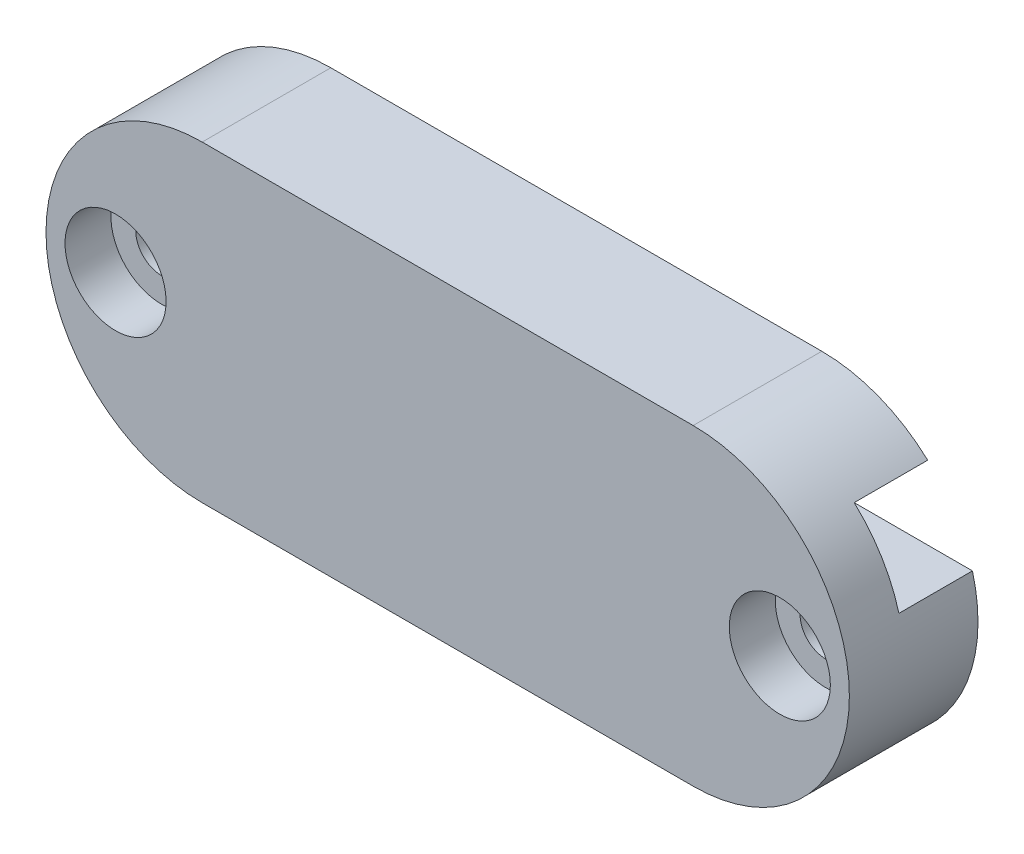
from build123d import *

# Parameters (mm, degrees)
BOSS_EXTRUDE1_DEPTH     = 7
SKETCH3_W               = 8
SKETCH3_H               = 4
CUT_EXTRUDE1_DEPTH      = 6.459407384
CUT_EXTRUDE1_DEPTH_BACK = 39.259407384
SKETCH6_R               = 1.4
CUT_EXTRUDE3_DEPTH      = 1
CUT_EXTRUDE3_DEPTH_BACK = 8
SKETCH8_R               = 2.75
CUT_EXTRUDE4_DEPTH      = 1
CUT_EXTRUDE4_DEPTH_BACK = 2.5


with BuildPart() as part:
    # Sketch1 → Boss-Extrude1 (new body)
    with BuildSketch(Plane.XY):
        with BuildLine():
            Line((-13.359407384, -8.5), (13.359407384, -8.5))
            ThreePointArc((13.359407384, -8.5), (21.859407384, 0), (13.359407384, 8.5))
            Line((13.359407384, 8.5), (-13.359407384, 8.5))
            ThreePointArc((-13.359407384, 8.5), (-21.859407384, 0), (-13.359407384, -8.5))
        make_face()
    extrude(amount=BOSS_EXTRUDE1_DEPTH)

    # Sketch3 → Cut-Extrude1 (cut, two sides)
    with BuildSketch(Plane(origin=(16.4, 0, 0), x_dir=(0, 0, -1), z_dir=(1, 0, 0))) as cut_extrude1_sk:
        with Locations((0, 4.247574753)):
            Rectangle(SKETCH3_W, SKETCH3_H)
    extrude(amount=CUT_EXTRUDE1_DEPTH, mode=Mode.SUBTRACT)
    extrude(cut_extrude1_sk.sketch, amount=-CUT_EXTRUDE1_DEPTH_BACK, mode=Mode.SUBTRACT)

    # Sketch6 → Cut-Extrude3 (cut, two sides)
    with BuildSketch(Plane(origin=(0, 0, 0), x_dir=(-1, 0, 0), z_dir=(0, 0, -1))) as cut_extrude3_sk:
        with Locations((-18.075, 0)):
            Circle(SKETCH6_R)
        with Locations((18.075, 0)):
            Circle(SKETCH6_R)
    extrude(amount=CUT_EXTRUDE3_DEPTH, mode=Mode.SUBTRACT)
    extrude(cut_extrude3_sk.sketch, amount=-CUT_EXTRUDE3_DEPTH_BACK, mode=Mode.SUBTRACT)

    # Sketch8 → Cut-Extrude4 (cut, two sides)
    with BuildSketch(Plane.XY.offset(7)) as cut_extrude4_sk:
        with Locations((-18.075, 0)):
            Circle(SKETCH8_R)
        with Locations((18.075, 0)):
            Circle(SKETCH8_R)
    extrude(amount=CUT_EXTRUDE4_DEPTH, mode=Mode.SUBTRACT)
    extrude(cut_extrude4_sk.sketch, amount=-CUT_EXTRUDE4_DEPTH_BACK, mode=Mode.SUBTRACT)


solid = part.part
